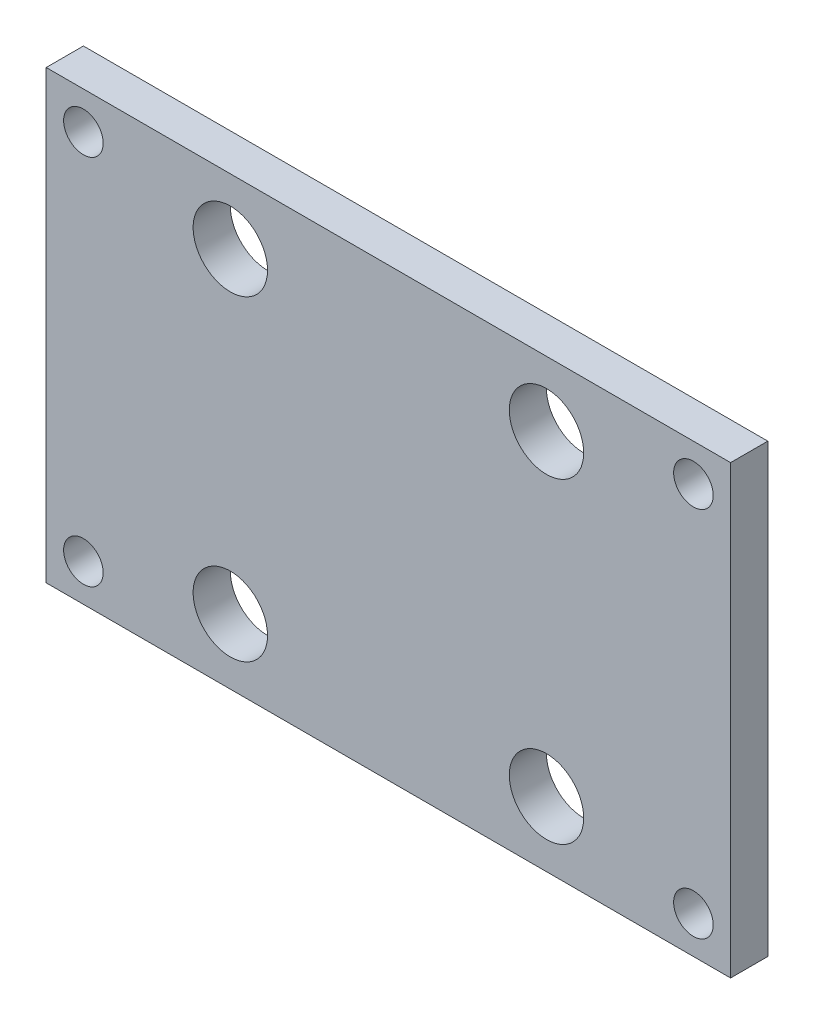
from build123d import *

# Parameters (mm, degrees)
SKETCH1_W                      = 116.84
SKETCH1_H                      = 76.2
EXTRUDE1_DEPTH                 = 6.35
F_1_4_CLEARANCE_HOLE1_D        = 6.7564
MIRROR2_COPY_1_D               = 6.7564
F_1_2_0_5_DIAMETER_HOLE1_D     = 12.7
F_1_2_0_5_DIAMETER_HOLE1_DEPTH = 17.78
F_1_2_0_5_DIAMETER_HOLE1_TIP   = 3.815464931


with BuildPart() as part:
    # Sketch1 → Extrude1 (new body)
    with BuildSketch(Plane.XY):
        Rectangle(SKETCH1_W, SKETCH1_H)
    extrude(amount=EXTRUDE1_DEPTH)

    # 1/4 Clearance Hole1 (through all)
    with Locations(Plane(origin=(-52.07, 31.75, 6.35), x_dir=(1, 0, 0), z_dir=(0, 0, 1))):
        with Locations((0, 0)):
            f_1_4_clearance_hole1 = Hole(F_1_4_CLEARANCE_HOLE1_D / 2)

    # Mirror1: 1/4 Clearance Hole1 across plane
    add(f_1_4_clearance_hole1.mirror(Plane.ZX), mode=Mode.SUBTRACT)

    # Mirror2: 1/4 Clearance Hole1 across plane
    add(f_1_4_clearance_hole1.mirror(Plane(origin=(0, 0, 0), x_dir=(0, 0, 1), z_dir=(1, 0, 0))), mode=Mode.SUBTRACT)

    # Mirror2 copy 1 (through all)
    with Locations(Plane(origin=(52.07, -31.75, 6.35), x_dir=(-1, 0, 0), z_dir=(0, 0, 1))):
        with Locations((0, 0)):
            Hole(MIRROR2_COPY_1_D / 2)

    # 1/2 (0.5) Diameter Hole1
    with Locations(Plane(origin=(-26.9875, 26.9875, 6.35), x_dir=(1, 0, 0), z_dir=(0, 0, 1))):
        with Locations((0, 0), (53.975, 0), (53.975, -53.975), (0, -53.975)):
            Hole(F_1_2_0_5_DIAMETER_HOLE1_D / 2, depth=F_1_2_0_5_DIAMETER_HOLE1_DEPTH)
            with Locations((0, 0, -(F_1_2_0_5_DIAMETER_HOLE1_DEPTH + F_1_2_0_5_DIAMETER_HOLE1_TIP / 2))):  # 118° drill point
                Cone(0, F_1_2_0_5_DIAMETER_HOLE1_D / 2, F_1_2_0_5_DIAMETER_HOLE1_TIP, mode=Mode.SUBTRACT)


solid = part.part
